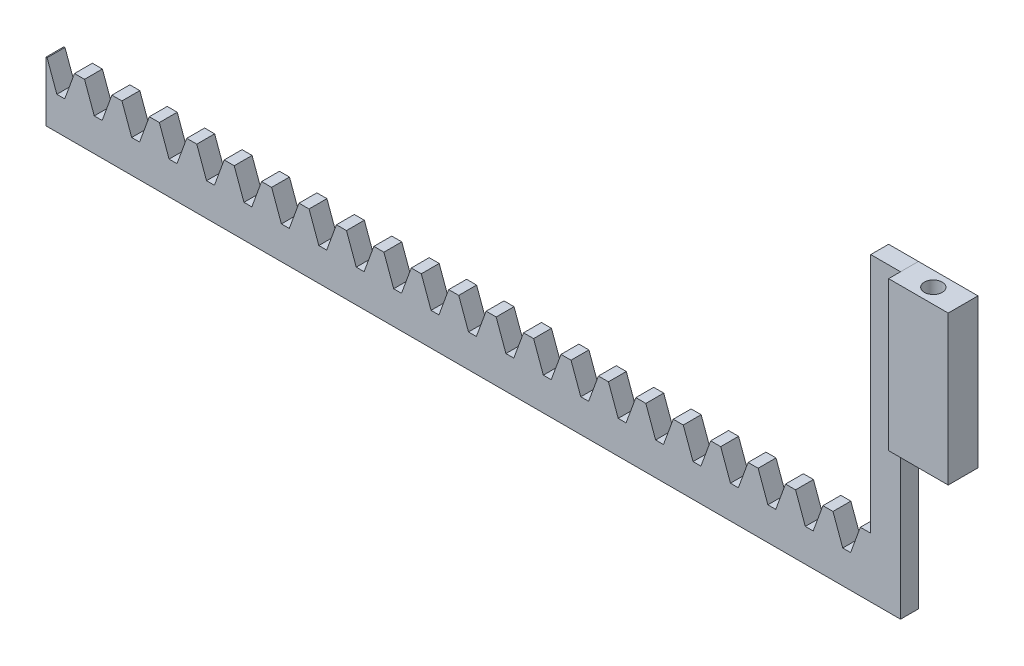
from build123d import *

# Parameters (mm, degrees)
SKETCH_1_W                 = 153.4
SKETCH_1_H                 = 10
EXTRUDE_1_DEPTH            = 3
CUT_EXTRUDE_1_DEPTH        = 4
PATTERN_LINEAR_1_COUNT     = 21
PATTERN_LINEAR_1_PITCH     = 6.28
PATTERN_LINEAR_1_COL_COUNT = 2
PATTERN_LINEAR_1_COL_PITCH = 6.28
SKETCH_3_W                 = 10
SKETCH_3_H                 = 3
CUT_EXTRUDE_2_DEPTH        = 11
SKETCH_4_W                 = 5
SKETCH_4_H                 = 3
EXTRUDE_2_DEPTH            = 40.5
SKETCH_5_W                 = 10
SKETCH_5_H                 = 25
EXTRUDE_3_DEPTH            = 5
SKETCH_6_R                 = 1.5
CUT_EXTRUDE_3_DEPTH        = 5
SKETCH_7_R                 = 1.5
CUT_EXTRUDE_4_DEPTH        = 5


with BuildPart() as part:
    # 스케치1 → 보스-돌출1 (new body)
    with BuildSketch(Plane.XY):
        with Locations((0, 5)):
            Rectangle(SKETCH_1_W, SKETCH_1_H)
    extrude(amount=-EXTRUDE_1_DEPTH)

    # 스케치2 → 컷-돌출1 (cut, through all)
    with BuildSketch(Plane.XY):
        Polygon((-68.600074414, 5.5), (-67.279925586, 5.5), (-65.642059531, 10), (-70.237940469, 10), align=None)
    cut_extrude_1 = extrude(amount=-CUT_EXTRUDE_1_DEPTH, mode=Mode.SUBTRACT)

    # 선형 패턴1: 컷-돌출1 ×21
    with Locations(*[(i * PATTERN_LINEAR_1_PITCH, 0, 0) for i in range(1, PATTERN_LINEAR_1_COUNT)]):
        add(cut_extrude_1, mode=Mode.SUBTRACT)

    # 선형 패턴1 col: 컷-돌출1 ×2
    with Locations(*[(-i * PATTERN_LINEAR_1_COL_PITCH, 0, 0) for i in range(1, PATTERN_LINEAR_1_COL_COUNT)]):
        add(cut_extrude_1, mode=Mode.SUBTRACT)

    # 스케치3 → 컷-돌출2 (cut, through all)
    with BuildSketch(Plane.XZ):
        with Locations((71.7, -1.5)):
            Rectangle(SKETCH_3_W, SKETCH_3_H)
    extrude(amount=-CUT_EXTRUDE_2_DEPTH, mode=Mode.SUBTRACT)

    # 스케치4 → 보스-돌출2 (add)
    with BuildSketch(Plane(origin=(0, 10, 0), x_dir=(1, 0, 0), z_dir=(0, 1, 0))):
        with Locations((64.2, 1.5)):
            Rectangle(SKETCH_4_W, SKETCH_4_H)
    extrude(amount=EXTRUDE_2_DEPTH)


with BuildPart() as body_2:
    # 스케치5 → 보스-돌출3 (new body)
    with BuildSketch(Plane(origin=(0, 0, -3), x_dir=(-1, 0, 0), z_dir=(0, 0, -1))):
        with Locations((-71.7, 38)):
            Rectangle(SKETCH_5_W, SKETCH_5_H)
    extrude(amount=-EXTRUDE_3_DEPTH)

    # 스케치6 → 컷-돌출3 (cut)
    with BuildSketch(Plane(origin=(0, 50.5, 0), x_dir=(1, 0, 0), z_dir=(0, 1, 0))):
        with Locations((71.7, 0.5)):
            Circle(SKETCH_6_R)
    extrude(amount=-CUT_EXTRUDE_3_DEPTH, mode=Mode.SUBTRACT)

    # 스케치7 → 컷-돌출4 (cut)
    with BuildSketch(Plane(origin=(0, 25.5, 0), x_dir=(-1, 0, 0), z_dir=(0, -1, 0))):
        with Locations((-71.7, 0.5)):
            Circle(SKETCH_7_R)
    extrude(amount=-CUT_EXTRUDE_4_DEPTH, mode=Mode.SUBTRACT)


solid = Compound([part.part, body_2.part])
